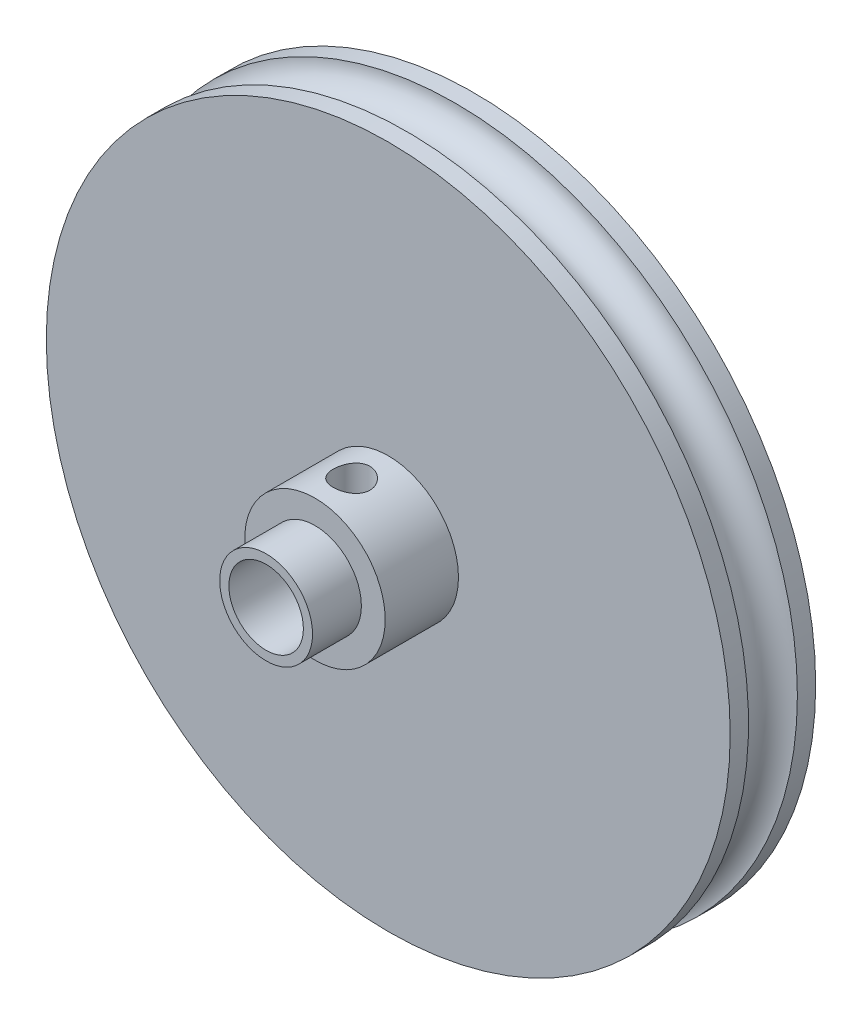
from build123d import *

# Parameters (mm, degrees)
ESQUISSE1_R             = 28
BOSS_EXTRU_1_DEPTH      = 7
ESQUISSE2_R             = 3.8
BOSS_EXTRU_2_DEPTH      = 10
ESQUISSE3_R             = 3.05
ENL_V_MAT_EXTRU_1_DEPTH = 18
ESQUISSE4_R             = 2
ESQUISSE5_R             = 5.75
ESQUISSE5_R_2           = 3.8
BOSS_EXTRU_3_DEPTH      = 6
ENL_V_MAT_EXTRU_2_REACH = 30
ESQUISSE6_R             = 1.5


with BuildPart() as part:
    # Esquisse1 → Boss.-Extru.1 (new body)
    with BuildSketch(Plane.XY):
        Circle(ESQUISSE1_R)
    extrude(amount=BOSS_EXTRU_1_DEPTH)

    # Esquisse2 → Boss.-Extru.2 (add)
    with BuildSketch(Plane.XY.offset(7)):
        Circle(ESQUISSE2_R)
    extrude(amount=BOSS_EXTRU_2_DEPTH)

    # Esquisse3 → Enlèv. mat.-Extru.1 (cut, through all)
    with BuildSketch(Plane.XY.offset(17)):
        Circle(ESQUISSE3_R)
    extrude(amount=-ENL_V_MAT_EXTRU_1_DEPTH, mode=Mode.SUBTRACT)

    # Esquisse4 → Enlèvement de matière-Révolution1 (revolve, cut)
    with BuildSketch(Plane(origin=(0, 0, 0), x_dir=(0, 0, -1), z_dir=(1, 0, 0))):
        with Locations((-3.5, 28)):
            Circle(ESQUISSE4_R)
    revolve(axis=Axis((0, 0, 0), (0, 0, 1)), mode=Mode.SUBTRACT)

    # Esquisse5 → Boss.-Extru.3 (add)
    with BuildSketch(Plane.XY.offset(7)):
        Circle(ESQUISSE5_R)
        Circle(ESQUISSE5_R_2, mode=Mode.SUBTRACT)
    extrude(amount=BOSS_EXTRU_3_DEPTH)

    # Esquisse6 → Enlèv. mat.-Extru.2 (cut, up to next)
    with BuildSketch(Plane(origin=(0, 0, 0), x_dir=(1, 0, 0), z_dir=(0, 1, 0)), mode=Mode.PRIVATE) as enl_v_mat_extru_2_sk1:
        with Locations((0, -10)):
            Circle(ESQUISSE6_R)
    enl_v_mat_extru_2_tool1 = extrude(enl_v_mat_extru_2_sk1.sketch, amount=ENL_V_MAT_EXTRU_2_REACH, mode=Mode.PRIVATE) & part.part
    add(enl_v_mat_extru_2_tool1.solids().sort_by_distance((0, 0, 10))[0], mode=Mode.SUBTRACT)


solid = part.part
